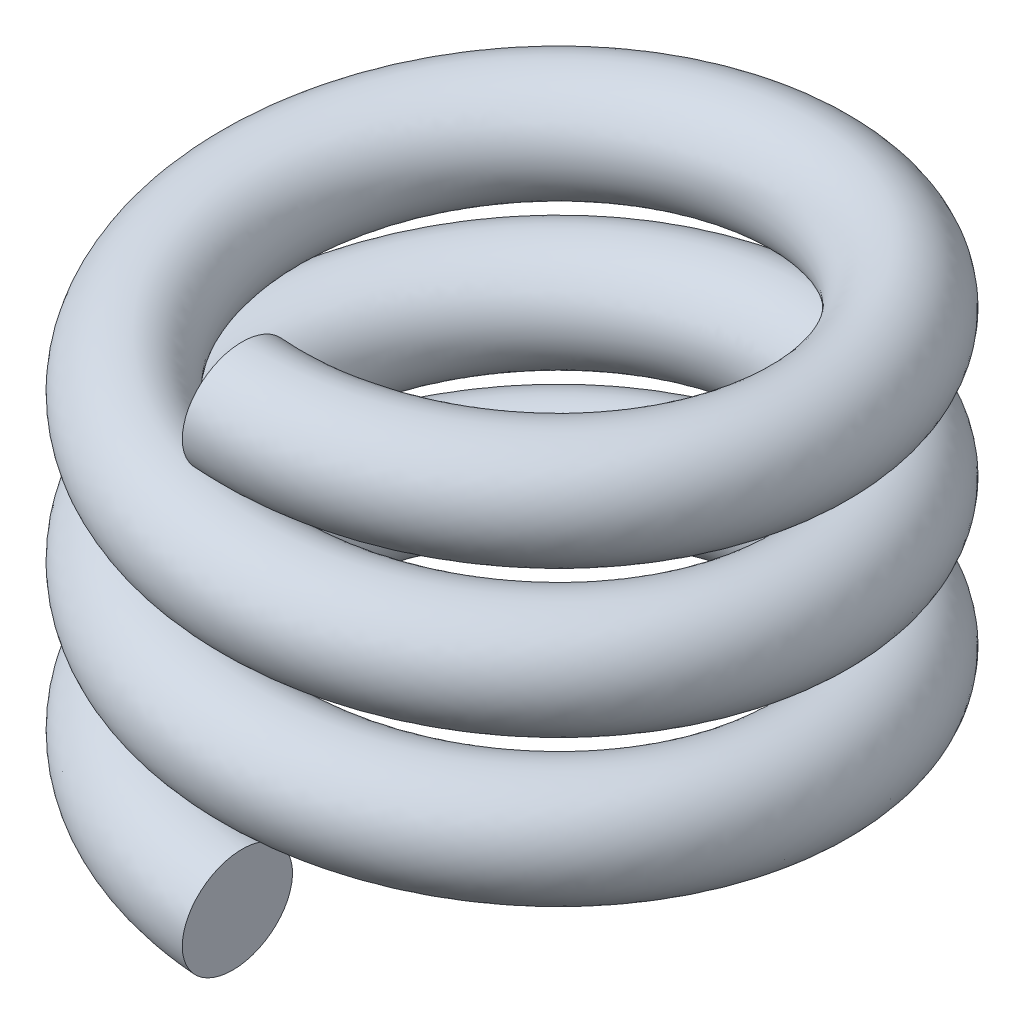
from build123d import *

# Parameters (mm, degrees)
SWEEP1_PITCH     = 13.333333333
SWEEP1_HEIGHT    = 40
SWEEP1_RADIUS    = 25
SWEEP1_PROFILE_R = 5


with BuildPart() as part:
    # Sweep1: sweep along a helix
    with BuildLine() as sweep1_path:
        Helix(SWEEP1_PITCH, SWEEP1_HEIGHT, SWEEP1_RADIUS, center=(0, 0, 0), direction=(0, 1, 0), lefthand=True)
    # Sweep1 profile (on start of the path) → Sweep1 (sweep)
    with BuildSketch(Plane(origin=(0, 0, 25), x_dir=(-0.084578487, -0.99641682, 0), z_dir=(-0.99641682, 0.084578487, 0))):
        Circle(SWEEP1_PROFILE_R)
    sweep(path=sweep1_path.line, is_frenet=True)


solid = part.part
